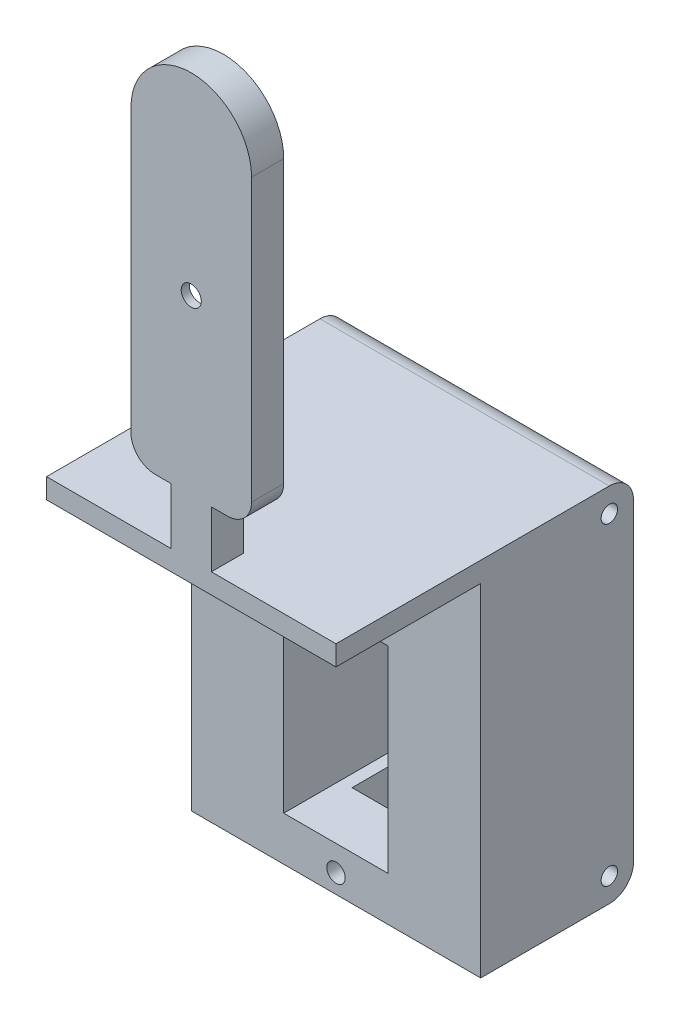
from build123d import *

# Parameters (mm, degrees)
EXTRUDE_1_DEPTH     = 4
CUT_EXTRUDE_1_DEPTH = 3
SKETCH_5_R          = 1.25
CUT_EXTRUDE_2_DEPTH = 12.4
SKETCH_13_W         = 36
SKETCH_13_H         = 45
EXTRUDE_2_DEPTH     = 37
SKETCH_14_W         = 13
SKETCH_14_H         = 24.5
CUT_EXTRUDE_3_DEPTH = 35
SKETCH_15_R         = 1.15
CUT_EXTRUDE_4_DEPTH = 31
SKETCH_16_W         = 10
SKETCH_16_H         = 8
CUT_EXTRUDE_5_DEPTH = 8
SKETCH_17_W         = 36
SKETCH_17_H         = 42.5
CUT_EXTRUDE_6_DEPTH = 18
SKETCH_23_R         = 1.025
CUT_EXTRUDE_7_DEPTH = 5
SKETCH_24_R         = 1.025
CUT_EXTRUDE_8_DEPTH = 5
FILLET_1_R          = 3
FILLET_2_R          = 3
FILLET_3_R          = 3
FILLET_4_R          = 3


with BuildPart() as part:
    # 草圖1 → 填料-伸長1 (new body)
    with BuildSketch(Plane.XY):
        with BuildLine():
            Line((7.5, 17), (7.5, 55))
            ThreePointArc((7.5, 55), (0, 62.5), (-7.5, 55))
            Line((-7.5, 55), (-7.5, 17))
            Line((-7.5, 17), (-2.5, 17))
            Line((-2.5, 17), (-2.5, 15))
            Line((-2.5, 15), (-2.5, 10))
            Line((-2.5, 10), (2.5, 10))
            Line((2.5, 10), (2.5, 15))
            Line((2.5, 15), (2.5, 17))
            Line((2.5, 17), (7.5, 17))
        make_face()
    extrude(amount=EXTRUDE_1_DEPTH)

    # 草圖3 → 除料-伸長1 (cut)
    with BuildSketch(Plane.XY):
        with BuildLine():
            ThreePointArc((-2.132795501, 56), (0, 58.132795501), (2.132795501, 56))
            Line((2.132795501, 56), (5, 38.5))
            Line((5, 38.5), (2.114741289, 20.658021353))
            ThreePointArc((2.114741289, 20.658021353), (-0.171540182, 18.864665347), (-2.142213835, 21))
            Line((-2.142213835, 21), (-5, 38.5))
            Line((-5, 38.5), (-2.132795501, 56))
        make_face()
    extrude(amount=CUT_EXTRUDE_1_DEPTH, mode=Mode.SUBTRACT)

    # 草圖5 → 除料-伸長2 (cut)
    with BuildSketch(Plane.XY):
        with Locations((0, 38.5)):
            Circle(SKETCH_5_R)
    extrude(amount=CUT_EXTRUDE_2_DEPTH, mode=Mode.SUBTRACT)

    # 草圖13 → 填料-伸長2 (add)
    with BuildSketch(Plane.XY.offset(4)):
        with Locations((0, -12.5)):
            Rectangle(SKETCH_13_W, SKETCH_13_H)
    extrude(amount=-EXTRUDE_2_DEPTH)

    # 草圖14 → 除料-伸長3 (cut)
    with BuildSketch(Plane(origin=(0, 0, 4), x_dir=(-1, 0, 0), z_dir=(0, 0, -1))):
        with Locations((0, -17.25)):
            Rectangle(SKETCH_14_W, SKETCH_14_H)
    extrude(amount=CUT_EXTRUDE_3_DEPTH, mode=Mode.SUBTRACT)

    # 草圖15 → 除料-伸長4 (cut)
    with BuildSketch(Plane.XY.offset(4)):
        with Locations((0, -1.85)):
            Circle(SKETCH_15_R)
        with Locations((0, -32.65)):
            Circle(SKETCH_15_R)
    extrude(amount=-CUT_EXTRUDE_4_DEPTH, mode=Mode.SUBTRACT)

    # 草圖16 → 除料-伸長5 (cut)
    with BuildSketch(Plane(origin=(0, -35, 0), x_dir=(-1, 0, 0), z_dir=(0, -1, 0))):
        with Locations((0, 25)):
            Rectangle(SKETCH_16_W, SKETCH_16_H)
    extrude(amount=-CUT_EXTRUDE_5_DEPTH, mode=Mode.SUBTRACT)

    # 草圖17 → 除料-伸長6 (cut)
    with BuildSketch(Plane.XY.offset(4)):
        with Locations((0, -13.75)):
            Rectangle(SKETCH_17_W, SKETCH_17_H)
    extrude(amount=-CUT_EXTRUDE_6_DEPTH, mode=Mode.SUBTRACT)

    # 草圖23 → 除料-伸長7 (cut)
    with BuildSketch(Plane.ZY.offset(18)):
        with Locations((-30, 7)):
            Circle(SKETCH_23_R)
        with Locations((-30, -32)):
            Circle(SKETCH_23_R)
    extrude(amount=-CUT_EXTRUDE_7_DEPTH, mode=Mode.SUBTRACT)

    # 草圖24 → 除料-伸長8 (cut)
    with BuildSketch(Plane(origin=(18, 0, 0), x_dir=(0, 0, -1), z_dir=(1, 0, 0))):
        with Locations((30, 7)):
            Circle(SKETCH_24_R)
        with Locations((30, -32)):
            Circle(SKETCH_24_R)
    extrude(amount=-CUT_EXTRUDE_8_DEPTH, mode=Mode.SUBTRACT)

    # 圓角1
    fillet_1_edges = [part.edges().sort_by_distance(p)[0] for p in [
        (7.5, 17, 2),
    ]]
    fillet(fillet_1_edges, radius=FILLET_1_R)

    # 圓角2
    fillet_2_edges = [part.edges().sort_by_distance(p)[0] for p in [
        (-7.5, 17, 2),
    ]]
    fillet(fillet_2_edges, radius=FILLET_2_R)

    # 圓角3
    fillet_3_edges = [part.edges().sort_by_distance(p)[0] for p in [
        (0, 10, -33),
    ]]
    fillet(fillet_3_edges, radius=FILLET_3_R)

    # 圓角4
    fillet_4_edges = [part.edges().sort_by_distance(p)[0] for p in [
        (0, -35, -33),
    ]]
    fillet(fillet_4_edges, radius=FILLET_4_R)


solid = part.part
